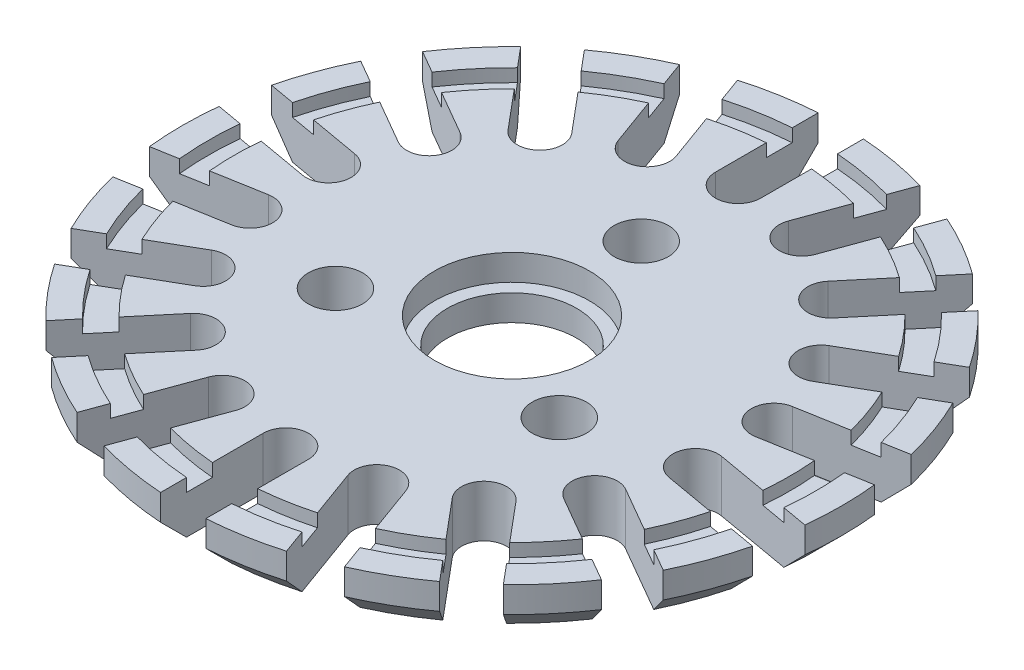
from build123d import *

# Parameters (mm, degrees)
ESBO_O1_R                = 5
RESSALTO_EXTRUS_O1_DEPTH = 4
ESBO_O2_R                = 6
CORTE_EXTRUS_O1_DEPTH    = 2
ESBO_O3_R                = 23.5
ESBO_O3_R_2              = 21.5
CORTE_EXTRUS_O2_DEPTH    = 1
CHANFRO1_SIZE            = 2
ESBO_O4_R                = 2.095
CORTE_EXTRUS_O3_DEPTH    = 5
CORTE_EXTRUS_O4_DEPTH    = 0.42


with BuildPart() as part:
    # Esboço1 → Ressalto-extrusão1 (new body)
    with BuildSketch(Plane(origin=(0, 0, 0), x_dir=(1, 0, 0), z_dir=(0, 1, 0))):
        with BuildLine():
            Line((1.75, 17.5), (1.75, 25.43988011))
            ThreePointArc((1.75, 25.43988011), (4.428028531, 25.112597702), (7.056489355, 24.504202864))
            Line((7.056489355, 24.504202864), (4.340890422, 17.043156115))
            ThreePointArc((4.340890422, 17.043156115), (5.386817257, 14.800158777), (7.629814595, 15.846085613))
            Line((7.629814595, 15.846085613), (10.345413528, 23.307132362))
            ThreePointArc((10.345413528, 23.307132362), (12.75, 22.083647797), (15.011861951, 20.612957109))
            Line((15.011861951, 20.612957109), (9.908205394, 14.530656072))
            ThreePointArc((9.908205394, 14.530656072), (10.123904853, 12.065199979), (12.589360945, 12.280899438))
            Line((12.589360945, 12.280899438), (17.693017502, 18.363200475))
            ThreePointArc((17.693017502, 18.363200475), (19.5341333, 16.391084047), (21.156582444, 14.235484512))
            Line((21.156582444, 14.235484512), (14.280444566, 10.265544457))
            ThreePointArc((14.280444566, 10.265544457), (13.63990011, 7.875), (16.030444566, 7.234455543))
            Line((16.030444566, 7.234455543), (22.906582444, 11.204395598))
            ThreePointArc((22.906582444, 11.204395598), (23.96216183, 8.721513655), (24.749506857, 6.141002389))
            Line((24.749506857, 6.141002389), (16.930251367, 4.762256677))
            ThreePointArc((16.930251367, 4.762256677), (15.51072211, 2.734958798), (17.538019989, 1.315429541))
            Line((17.538019989, 1.315429541), (25.357275479, 2.694175253))
            ThreePointArc((25.357275479, 2.694175253), (25.5, 0), (25.357275479, -2.694175253))
            Line((25.357275479, -2.694175253), (17.538019989, -1.315429541))
            ThreePointArc((17.538019989, -1.315429541), (15.51072211, -2.734958798), (16.930251367, -4.762256677))
            Line((16.930251367, -4.762256677), (24.749506857, -6.141002389))
            ThreePointArc((24.749506857, -6.141002389), (23.96216183, -8.721513655), (22.906582444, -11.204395598))
            Line((22.906582444, -11.204395598), (16.030444566, -7.234455543))
            ThreePointArc((16.030444566, -7.234455543), (13.63990011, -7.875), (14.280444566, -10.265544457))
            Line((14.280444566, -10.265544457), (21.156582444, -14.235484512))
            ThreePointArc((21.156582444, -14.235484512), (19.5341333, -16.391084047), (17.693017502, -18.363200475))
            Line((17.693017502, -18.363200475), (12.589360945, -12.280899438))
            ThreePointArc((12.589360945, -12.280899438), (10.123904853, -12.065199979), (9.908205394, -14.530656072))
            Line((9.908205394, -14.530656072), (15.011861951, -20.612957109))
            ThreePointArc((15.011861951, -20.612957109), (12.75, -22.083647797), (10.345413528, -23.307132362))
            Line((10.345413528, -23.307132362), (7.629814595, -15.846085613))
            ThreePointArc((7.629814595, -15.846085613), (5.386817257, -14.800158777), (4.340890422, -17.043156115))
            Line((4.340890422, -17.043156115), (7.056489355, -24.504202864))
            ThreePointArc((7.056489355, -24.504202864), (4.428028531, -25.112597702), (1.75, -25.43988011))
            Line((1.75, -25.43988011), (1.75, -17.5))
            ThreePointArc((1.75, -17.5), (0, -15.75), (-1.75, -17.5))
            Line((-1.75, -17.5), (-1.75, -25.43988011))
            ThreePointArc((-1.75, -25.43988011), (-4.428028531, -25.112597702), (-7.056489355, -24.504202864))
            Line((-7.056489355, -24.504202864), (-4.340890422, -17.043156115))
            ThreePointArc((-4.340890422, -17.043156115), (-5.386817257, -14.800158777), (-7.629814595, -15.846085613))
            Line((-7.629814595, -15.846085613), (-10.345413528, -23.307132362))
            ThreePointArc((-10.345413528, -23.307132362), (-12.75, -22.083647797), (-15.011861951, -20.612957109))
            Line((-15.011861951, -20.612957109), (-9.908205394, -14.530656072))
            ThreePointArc((-9.908205394, -14.530656072), (-10.123904853, -12.065199979), (-12.589360945, -12.280899438))
            Line((-12.589360945, -12.280899438), (-17.693017502, -18.363200475))
            ThreePointArc((-17.693017502, -18.363200475), (-19.5341333, -16.391084047), (-21.156582444, -14.235484512))
            Line((-21.156582444, -14.235484512), (-14.280444566, -10.265544457))
            ThreePointArc((-14.280444566, -10.265544457), (-13.63990011, -7.875), (-16.030444566, -7.234455543))
            Line((-16.030444566, -7.234455543), (-22.906582444, -11.204395598))
            ThreePointArc((-22.906582444, -11.204395598), (-23.96216183, -8.721513655), (-24.749506857, -6.141002389))
            Line((-24.749506857, -6.141002389), (-16.930251367, -4.762256677))
            ThreePointArc((-16.930251367, -4.762256677), (-15.51072211, -2.734958798), (-17.538019989, -1.315429541))
            Line((-17.538019989, -1.315429541), (-25.357275479, -2.694175253))
            ThreePointArc((-25.357275479, -2.694175253), (-25.5, 0), (-25.357275479, 2.694175253))
            Line((-25.357275479, 2.694175253), (-17.538019989, 1.315429541))
            ThreePointArc((-17.538019989, 1.315429541), (-15.51072211, 2.734958798), (-16.930251367, 4.762256677))
            Line((-16.930251367, 4.762256677), (-24.749506857, 6.141002389))
            ThreePointArc((-24.749506857, 6.141002389), (-23.96216183, 8.721513655), (-22.906582444, 11.204395598))
            Line((-22.906582444, 11.204395598), (-16.030444566, 7.234455543))
            ThreePointArc((-16.030444566, 7.234455543), (-13.63990011, 7.875), (-14.280444566, 10.265544457))
            Line((-14.280444566, 10.265544457), (-21.156582444, 14.235484512))
            ThreePointArc((-21.156582444, 14.235484512), (-19.5341333, 16.391084047), (-17.693017502, 18.363200475))
            Line((-17.693017502, 18.363200475), (-12.589360945, 12.280899438))
            ThreePointArc((-12.589360945, 12.280899438), (-10.123904853, 12.065199979), (-9.908205394, 14.530656072))
            Line((-9.908205394, 14.530656072), (-15.011861951, 20.612957109))
            ThreePointArc((-15.011861951, 20.612957109), (-12.75, 22.083647797), (-10.345413528, 23.307132362))
            Line((-10.345413528, 23.307132362), (-7.629814595, 15.846085613))
            ThreePointArc((-7.629814595, 15.846085613), (-5.386817257, 14.800158777), (-4.340890422, 17.043156115))
            Line((-4.340890422, 17.043156115), (-7.056489355, 24.504202864))
            ThreePointArc((-7.056489355, 24.504202864), (-4.428028531, 25.112597702), (-1.75, 25.43988011))
            Line((-1.75, 25.43988011), (-1.75, 17.5))
            ThreePointArc((-1.75, 17.5), (0, 15.75), (1.75, 17.5))
        make_face()
        Circle(ESBO_O1_R, mode=Mode.SUBTRACT)
    extrude(amount=RESSALTO_EXTRUS_O1_DEPTH)

    # Esboço2 → Corte-extrusão1 (cut)
    with BuildSketch(Plane(origin=(0, 4, 0), x_dir=(1, 0, 0), z_dir=(0, 1, 0))):
        Circle(ESBO_O2_R)
    extrude(amount=-CORTE_EXTRUS_O1_DEPTH, mode=Mode.SUBTRACT)

    # Esboço3 → Corte-extrusão2 (cut)
    with BuildSketch(Plane(origin=(0, 4, 0), x_dir=(1, 0, 0), z_dir=(0, 1, 0))):
        Circle(ESBO_O3_R)
        Circle(ESBO_O3_R_2, mode=Mode.SUBTRACT)
    extrude(amount=-CORTE_EXTRUS_O2_DEPTH, mode=Mode.SUBTRACT)

    # Chanfro1
    chanfro1_edges = [part.edges().sort_by_distance(p)[0] for p in [
        (4.428028531, 0, -25.112597702),
        (12.75, 0, -22.083647797),
        (19.5341333, 0, -16.391084047),
        (23.96216183, 0, -8.721513655),
        (25.5, 0, 0),
        (23.96216183, 0, 8.721513655),
        (19.5341333, 0, 16.391084047),
        (12.75, 0, 22.083647797),
        (4.428028531, 0, 25.112597702),
        (-4.428028531, 0, 25.112597702),
        (-12.75, 0, 22.083647797),
        (-19.5341333, 0, 16.391084047),
        (-23.96216183, 0, 8.721513655),
        (-25.5, 0, 0),
        (-23.96216183, 0, -8.721513655),
        (-19.5341333, 0, -16.391084047),
        (-12.75, 0, -22.083647797),
        (-4.428028531, 0, -25.112597702),
    ]]
    chamfer(chanfro1_edges, length=CHANFRO1_SIZE)

    # Esboço4 → Corte-extrusão3 (cut, through all)
    with BuildSketch(Plane.XZ):
        with Locations((0, -10)):
            Circle(ESBO_O4_R)
        with Locations((-8.660254038, 5)):
            Circle(ESBO_O4_R)
        with Locations((8.660254038, 5)):
            Circle(ESBO_O4_R)
    extrude(amount=-CORTE_EXTRUS_O3_DEPTH, mode=Mode.SUBTRACT)

    # Esboço5 → Corte-extrusão4 (cut)
    with BuildSketch(Plane.XZ):
        Polygon((11.430254038, 5), (10.045254038, 7.398890368), (7.275254038, 7.398890368), (5.890254038, 5), (7.275254038, 2.601109632), (10.045254038, 2.601109632), align=None)
        Polygon((-5.890254038, 5), (-7.275254038, 7.398890368), (-10.045254038, 7.398890368), (-11.430254038, 5), (-10.045254038, 2.601109632), (-7.275254038, 2.601109632), align=None)
        Polygon((2.77, -10), (1.385, -7.601109632), (-1.385, -7.601109632), (-2.77, -10), (-1.385, -12.398890368), (1.385, -12.398890368), align=None)
    extrude(amount=-CORTE_EXTRUS_O4_DEPTH, mode=Mode.SUBTRACT)


solid = part.part
